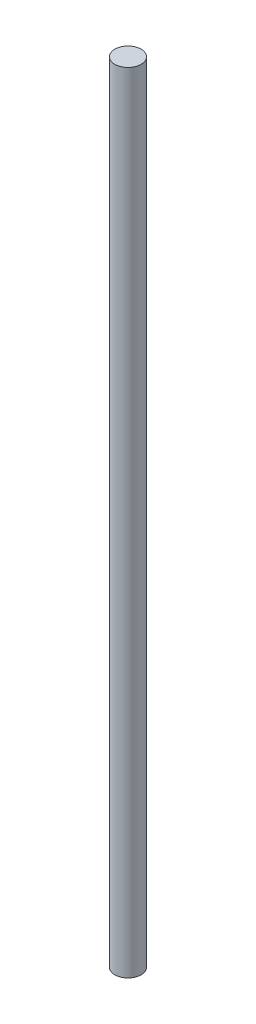
from build123d import *

# Parameters (mm, degrees)
SKETCH1_R           = 0.25
BOSS_EXTRUDE1_DEPTH = 7.5


with BuildPart() as part:
    # Sketch1 → Boss-Extrude1 (new body, symmetric)
    with BuildSketch(Plane(origin=(0, 0, 0), x_dir=(1, 0, 0), z_dir=(0, 1, 0))):
        Circle(SKETCH1_R)
    extrude(amount=BOSS_EXTRUDE1_DEPTH, both=True)


solid = part.part
